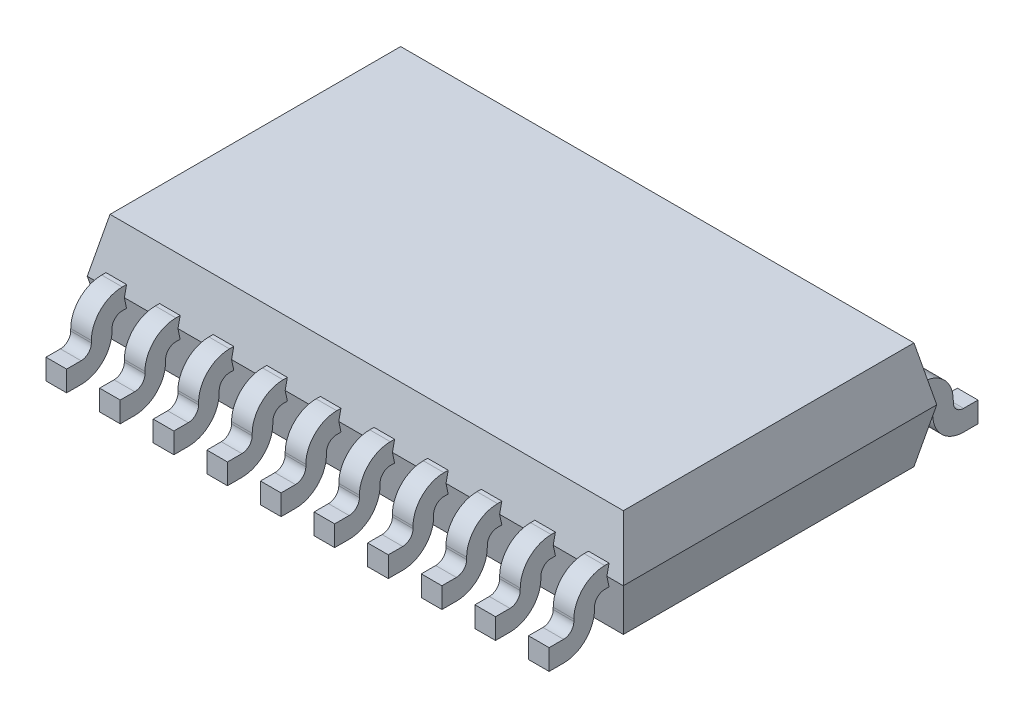
from build123d import *

# Parameters (mm, degrees)
SKETCH1_W                     = 13
SKETCH1_H                     = 7.6
BOSS_EXTRUDE1_DEPTH           = 1.3
BOSS_EXTRUDE1_TAPER           = 12
BOSS_EXTRUDE1_OTHER_WAY_DEPTH = 1.3
BOSS_EXTRUDE1_OTHER_WAY_TAPER = 12
SKETCH2_W                     = 0.5
SKETCH2_H                     = 0.5
BOSS_EXTRUDE3_DEPTH           = 0.8
BOSS_EXTRUDE3_DEPTH_BACK      = 1
SKETCH3_W                     = 0.5
SKETCH3_H                     = 0.5
BOSS_EXTRUDE4_DEPTH           = 1.05
SKETCH4_W                     = 0.5
SKETCH4_H                     = 0.5
BOSS_EXTRUDE5_DEPTH           = 0.6
FILLET1_R                     = 0.25
FILLET2_R                     = 0.75
LPATTERN2_COUNT               = 10
LPATTERN2_PITCH               = 1.3


with BuildPart() as part:
    # Sketch1 → Boss-Extrude1 (new body)
    with BuildSketch(Plane(origin=(0, 0, 0), x_dir=(1, 0, 0), z_dir=(0, 1, 0))):
        Rectangle(SKETCH1_W, SKETCH1_H)
    extrude(amount=BOSS_EXTRUDE1_DEPTH, taper=BOSS_EXTRUDE1_TAPER)

    # Sketch1 → Boss-Extrude1 other way (add)
    with BuildSketch(Plane(origin=(0, 0, 0), x_dir=(1, 0, 0), z_dir=(0, 1, 0))):
        Rectangle(SKETCH1_W, SKETCH1_H)
    extrude(amount=-BOSS_EXTRUDE1_OTHER_WAY_DEPTH, taper=BOSS_EXTRUDE1_OTHER_WAY_TAPER)


with BuildPart() as body_2:
    # Sketch2 → Boss-Extrude3 (new body, two sides)
    with BuildSketch(Plane.XY.offset(3.8)) as boss_extrude3_sk:
        with Locations((5.85, 0)):
            Rectangle(SKETCH2_W, SKETCH2_H)
    extrude(amount=BOSS_EXTRUDE3_DEPTH)
    extrude(boss_extrude3_sk.sketch, amount=-BOSS_EXTRUDE3_DEPTH_BACK)

    # Sketch3 → Boss-Extrude4 (add)
    with BuildSketch(Plane(origin=(0, -0.25, 0), x_dir=(-1, 0, 0), z_dir=(0, -1, 0))):
        with Locations((-5.85, -4.35)):
            Rectangle(SKETCH3_W, SKETCH3_H)
    extrude(amount=BOSS_EXTRUDE4_DEPTH)

    # Sketch4 → Boss-Extrude5 (add)
    with BuildSketch(Plane.XY.offset(4.6)):
        with Locations((5.85, -1.05)):
            Rectangle(SKETCH4_W, SKETCH4_H)
    extrude(amount=BOSS_EXTRUDE5_DEPTH)

    # Fillet1
    fillet1_edges = [body_2.edges().sort_by_distance(p)[0] for p in [
        (5.85, -0.25, 4.1),
        (5.85, -0.8, 4.6),
    ]]
    fillet(fillet1_edges, radius=FILLET1_R)

    # Fillet2
    fillet2_edges = [body_2.edges().sort_by_distance(p)[0] for p in [
        (5.85, 0.25, 4.6),
        (5.85, -1.3, 4.1),
    ]]
    fillet(fillet2_edges, radius=FILLET2_R)


with BuildPart() as lpattern2_1:
    # LPattern2: pattern copy
    add(body_2.part.moved(Location(Vector(-1, 0, 0) * (1 * LPATTERN2_PITCH))))


with BuildPart() as lpattern2_2:
    # LPattern2: pattern copy
    add(body_2.part.moved(Location(Vector(-1, 0, 0) * (2 * LPATTERN2_PITCH))))


with BuildPart() as lpattern2_3:
    # LPattern2: pattern copy
    add(body_2.part.moved(Location(Vector(-1, 0, 0) * (3 * LPATTERN2_PITCH))))


with BuildPart() as lpattern2_4:
    # LPattern2: pattern copy
    add(body_2.part.moved(Location(Vector(-1, 0, 0) * (4 * LPATTERN2_PITCH))))


with BuildPart() as lpattern2_5:
    # LPattern2: pattern copy
    add(body_2.part.moved(Location(Vector(-1, 0, 0) * (5 * LPATTERN2_PITCH))))


with BuildPart() as lpattern2_6:
    # LPattern2: pattern copy
    add(body_2.part.moved(Location(Vector(-1, 0, 0) * (6 * LPATTERN2_PITCH))))


with BuildPart() as lpattern2_7:
    # LPattern2: pattern copy
    add(body_2.part.moved(Location(Vector(-1, 0, 0) * (7 * LPATTERN2_PITCH))))


with BuildPart() as lpattern2_8:
    # LPattern2: pattern copy
    add(body_2.part.moved(Location(Vector(-1, 0, 0) * (8 * LPATTERN2_PITCH))))


with BuildPart() as lpattern2_9:
    # LPattern2: pattern copy
    add(body_2.part.moved(Location(Vector(-1, 0, 0) * (9 * LPATTERN2_PITCH))))


with BuildPart() as body_12:
    # Mirror2: mirrored copy
    add(lpattern2_7.part.mirror(Plane.XY))


with BuildPart() as body_13:
    # Mirror2 2: mirrored copy
    add(body_2.part.mirror(Plane.XY))


with BuildPart() as body_14:
    # Mirror2 3: mirrored copy
    add(lpattern2_1.part.mirror(Plane.XY))


with BuildPart() as body_15:
    # Mirror2 4: mirrored copy
    add(lpattern2_2.part.mirror(Plane.XY))


with BuildPart() as body_16:
    # Mirror2 5: mirrored copy
    add(lpattern2_3.part.mirror(Plane.XY))


with BuildPart() as body_17:
    # Mirror2 6: mirrored copy
    add(lpattern2_4.part.mirror(Plane.XY))


with BuildPart() as body_18:
    # Mirror2 7: mirrored copy
    add(lpattern2_5.part.mirror(Plane.XY))


with BuildPart() as body_19:
    # Mirror2 8: mirrored copy
    add(lpattern2_6.part.mirror(Plane.XY))


with BuildPart() as body_20:
    # Mirror2 9: mirrored copy
    add(lpattern2_8.part.mirror(Plane.XY))


with BuildPart() as body_21:
    # Mirror2 10: mirrored copy
    add(lpattern2_9.part.mirror(Plane.XY))


solid = Compound([part.part, body_2.part, lpattern2_1.part, lpattern2_2.part, lpattern2_3.part, lpattern2_4.part, lpattern2_5.part, lpattern2_6.part, lpattern2_7.part, lpattern2_8.part, lpattern2_9.part, body_12.part, body_13.part, body_14.part, body_15.part, body_16.part, body_17.part, body_18.part, body_19.part, body_20.part, body_21.part])
